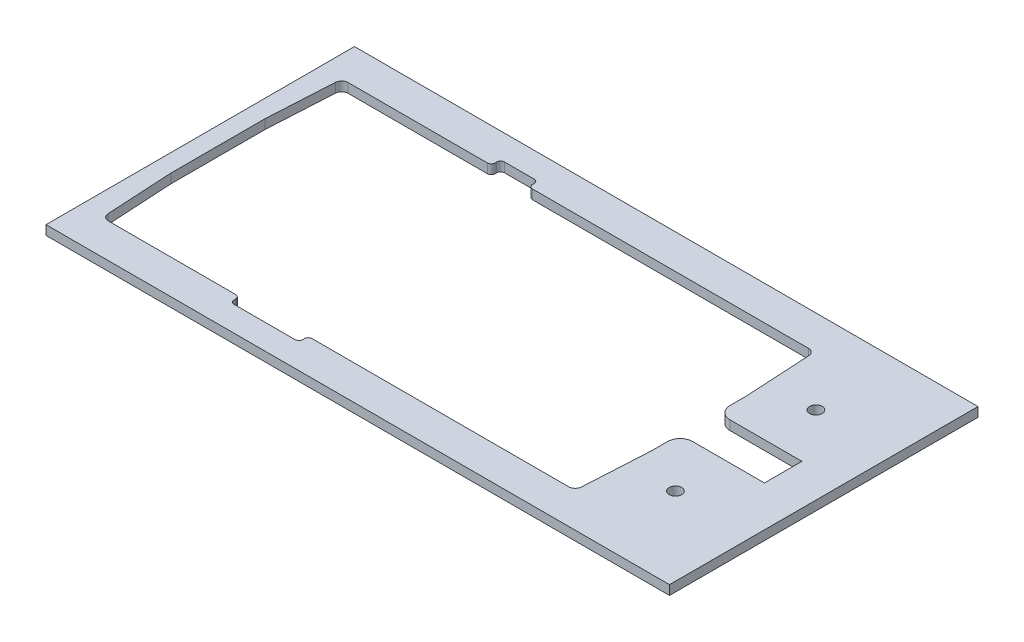
from build123d import *

# Parameters (mm, degrees)
SKETCH1_W           = 199.69
SKETCH1_H           = 98.8
SKETCH1_R           = 2
BOSS_EXTRUDE1_DEPTH = 3


with BuildPart() as part:
    # Sketch1 → Boss-Extrude1 (new body)
    with BuildSketch(Plane(origin=(0, 0, 0), x_dir=(1, 0, 0), z_dir=(0, 1, 0))):
        with Locations((49.702752105, -22.572203273)):
            Rectangle(SKETCH1_W, SKETCH1_H)
        with Locations((124.547752105, -0.072203273)):
            Circle(SKETCH1_R, mode=Mode.SUBTRACT)
        with Locations((124.547752105, -45.072203273)):
            Circle(SKETCH1_R, mode=Mode.SUBTRACT)
        with BuildLine():
            Line((-41.155575491, 15.827796727), (3.397752105, 15.827796727))
            ThreePointArc((3.397752105, 15.827796727), (4.281635581, 16.193913251), (4.647752105, 17.077796727))
            Line((4.647752105, 17.077796727), (4.647752105, 17.577796727))
            ThreePointArc((4.647752105, 17.577796727), (5.013868628, 18.461680204), (5.897752105, 18.827796727))
            Line((5.897752105, 18.827796727), (15.397752105, 18.827796727))
            ThreePointArc((15.397752105, 18.827796727), (16.281635581, 18.461680204), (16.647752105, 17.577796727))
            Line((16.647752105, 17.577796727), (16.647752105, 17.077796727))
            ThreePointArc((16.647752105, 17.077796727), (17.013868628, 16.193913251), (17.897752105, 15.827796727))
            Line((17.897752105, 15.827796727), (106.2510797, 15.827796727))
            ThreePointArc((106.2510797, 15.827796727), (107.693618601, 15.253929592), (108.347752105, 13.845969603))
            Line((108.347752105, 13.845969603), (109.547752105, -7.444930545))
            Line((109.547752105, -7.444930545), (109.547752105, -12.572203273))
            ThreePointArc((109.547752105, -12.572203273), (110.71932498, -15.400630397), (113.547752105, -16.572203273))
            Line((113.547752105, -16.572203273), (136.547694997, -16.572203273))
            Line((136.547694997, -16.572203273), (136.547694997, -28.572203273))
            Line((136.547694997, -28.572203273), (113.547752105, -28.572203273))
            ThreePointArc((113.547752105, -28.572203273), (110.71932498, -29.743776148), (109.547752105, -32.572203273))
            Line((109.547752105, -32.572203273), (109.547752105, -37.699476))
            Line((109.547752105, -37.699476), (108.347752105, -58.990376148))
            ThreePointArc((108.347752105, -58.990376148), (107.693618601, -60.398336137), (106.2510797, -60.972203273))
            Line((106.2510797, -60.972203273), (24.097694997, -60.972203273))
            ThreePointArc((24.097694997, -60.972203273), (23.21381152, -61.338319796), (22.847694997, -62.222203273))
            Line((22.847694997, -62.222203273), (22.847694997, -62.722203273))
            ThreePointArc((22.847694997, -62.722203273), (22.481578473, -63.606086749), (21.597694997, -63.972203273))
            Line((21.597694997, -63.972203273), (2.097694997, -63.972203273))
            ThreePointArc((2.097694997, -63.972203273), (1.21381152, -63.606086749), (0.847694997, -62.722203273))
            Line((0.847694997, -62.722203273), (0.847694997, -62.222203273))
            ThreePointArc((0.847694997, -62.222203273), (0.481578473, -61.338319796), (-0.402305003, -60.972203273))
            Line((-0.402305003, -60.972203273), (-41.155575491, -60.972203273))
            ThreePointArc((-41.155575491, -60.972203273), (-42.598114392, -60.398336137), (-43.252247895, -58.990376148))
            Line((-43.252247895, -58.990376148), (-44.452247895, -37.699476))
            Line((-44.452247895, -37.699476), (-44.452247895, -7.444930545))
            Line((-44.452247895, -7.444930545), (-43.252247895, 13.845969603))
            ThreePointArc((-43.252247895, 13.845969603), (-42.598114392, 15.253929592), (-41.155575491, 15.827796727))
        make_face(mode=Mode.SUBTRACT)
    extrude(amount=BOSS_EXTRUDE1_DEPTH)


solid = part.part
